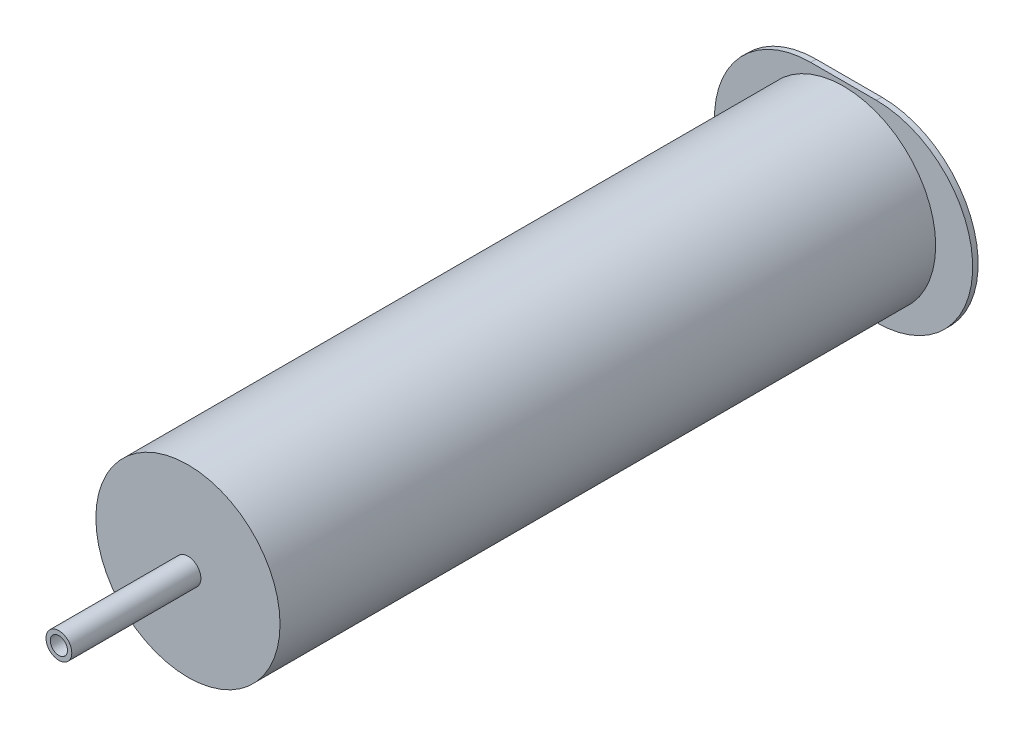
from build123d import *

# Parameters (mm, degrees)
BOSS_EXTRUDE1_DEPTH = 1.27
SKETCH2_R           = 21.405
BOSS_EXTRUDE2_DEPTH = 152.4
SKETCH3_R           = 20.5
CUT_EXTRUDE1_DEPTH  = 149.86
SKETCH4_R           = 3
SKETCH4_R_2         = 2
BOSS_EXTRUDE3_DEPTH = 30


with BuildPart() as part:
    # Sketch1 → Boss-Extrude1 (new body)
    with BuildSketch(Plane.XY):
        with BuildLine():
            Line((-7.64, 22.37), (7.64, 22.37))
            ThreePointArc((7.64, 22.37), (30.01, 0), (7.64, -22.37))
            Line((7.64, -22.37), (-7.64, -22.37))
            ThreePointArc((-7.64, -22.37), (-30.01, 0), (-7.64, 22.37))
        make_face()
    extrude(amount=BOSS_EXTRUDE1_DEPTH)

    # Sketch2 → Boss-Extrude2 (add)
    with BuildSketch(Plane.XY.offset(1.27)):
        Circle(SKETCH2_R)
    extrude(amount=BOSS_EXTRUDE2_DEPTH)

    # Sketch3 → Cut-Extrude1 (cut)
    with BuildSketch(Plane(origin=(0, 0, 0), x_dir=(-1, 0, 0), z_dir=(0, 0, -1))):
        Circle(SKETCH3_R)
    extrude(amount=-CUT_EXTRUDE1_DEPTH, mode=Mode.SUBTRACT)

    # Sketch4 → Boss-Extrude3 (add)
    with BuildSketch(Plane.XY.offset(153.67)):
        Circle(SKETCH4_R)
        Circle(SKETCH4_R_2, mode=Mode.SUBTRACT)
    extrude(amount=BOSS_EXTRUDE3_DEPTH)


solid = part.part
